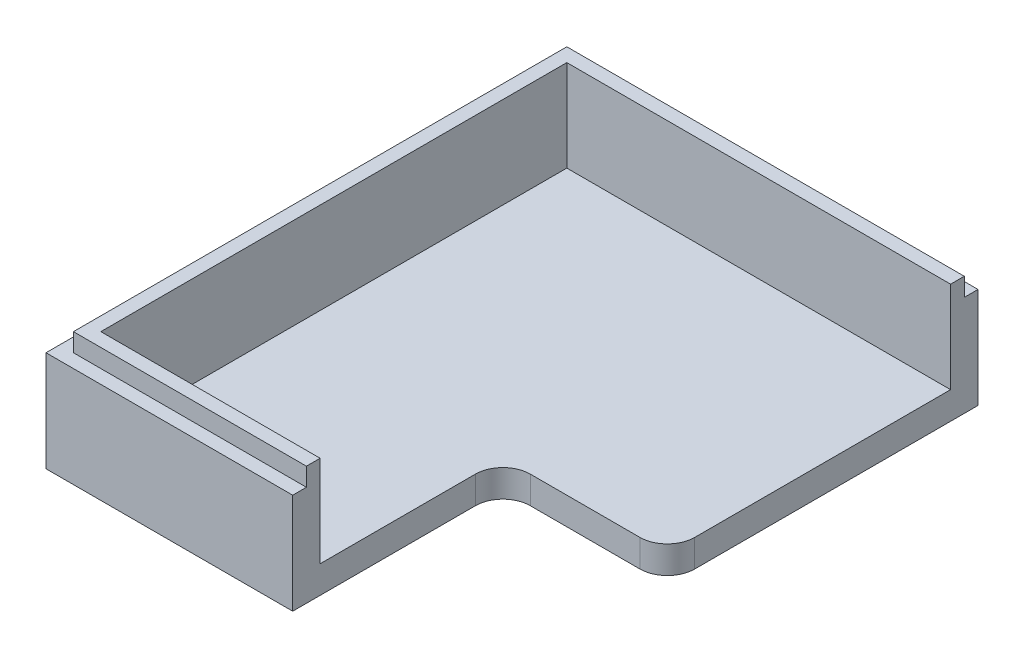
from build123d import *

# Parameters (mm, degrees)
SKETCH1_W           = 71
SKETCH1_H           = 57
BOSS_EXTRUDE1_DEPTH = 3
SKETCH2_W           = 71
SKETCH2_H           = 57
SKETCH2_W_2         = 65
SKETCH2_H_2         = 51
BOSS_EXTRUDE2_DEPTH = 8
SKETCH6_W           = 68
SKETCH6_H           = 54
SKETCH6_W_2         = 65
SKETCH6_H_2         = 51
BOSS_EXTRUDE5_DEPTH = 2
SKETCH7_W           = 26
SKETCH7_H           = 15.829787861
CUT_EXTRUDE2_DEPTH  = 58
SKETCH8_W           = 44
SKETCH8_H           = 23
CUT_EXTRUDE3_DEPTH  = 14
FILLET1_R           = 3


with BuildPart() as part:
    # Sketch1 → Boss-Extrude1 (new body)
    with BuildSketch(Plane(origin=(0, 0, 0), x_dir=(1, 0, 0), z_dir=(0, 1, 0))):
        Rectangle(SKETCH1_W, SKETCH1_H)
    extrude(amount=BOSS_EXTRUDE1_DEPTH)

    # Sketch2 → Boss-Extrude2 (add)
    with BuildSketch(Plane(origin=(0, 3, 0), x_dir=(1, 0, 0), z_dir=(0, 1, 0))):
        Rectangle(SKETCH2_W, SKETCH2_H)
        Rectangle(SKETCH2_W_2, SKETCH2_H_2, mode=Mode.SUBTRACT)
    extrude(amount=BOSS_EXTRUDE2_DEPTH)

    # Sketch6 → Boss-Extrude5 (add)
    with BuildSketch(Plane(origin=(0, 11, 0), x_dir=(1, 0, 0), z_dir=(0, 1, 0))):
        Rectangle(SKETCH6_W, SKETCH6_H)
        Rectangle(SKETCH6_W_2, SKETCH6_H_2, mode=Mode.SUBTRACT)
    extrude(amount=BOSS_EXTRUDE5_DEPTH)

    # Sketch7 → Cut-Extrude2 (cut, through all)
    with BuildSketch(Plane(origin=(0, 0, -28.5), x_dir=(-1, 0, 0), z_dir=(0, 0, -1))):
        with Locations((-22.5, 7.063052876)):
            Rectangle(SKETCH7_W, SKETCH7_H)
    extrude(amount=-CUT_EXTRUDE2_DEPTH, mode=Mode.SUBTRACT)

    # Sketch8 → Cut-Extrude3 (cut, through all)
    with BuildSketch(Plane.XZ):
        with Locations((13.5, 17)):
            Rectangle(SKETCH8_W, SKETCH8_H)
    extrude(amount=-CUT_EXTRUDE3_DEPTH, mode=Mode.SUBTRACT)

    # Fillet1
    fillet1_edges = [part.edges().sort_by_distance(p)[0] for p in [
        (-8.5, 1.5, 5.5),
        (9.5, 1.5, 5.5),
    ]]
    fillet(fillet1_edges, radius=FILLET1_R)


solid = part.part
